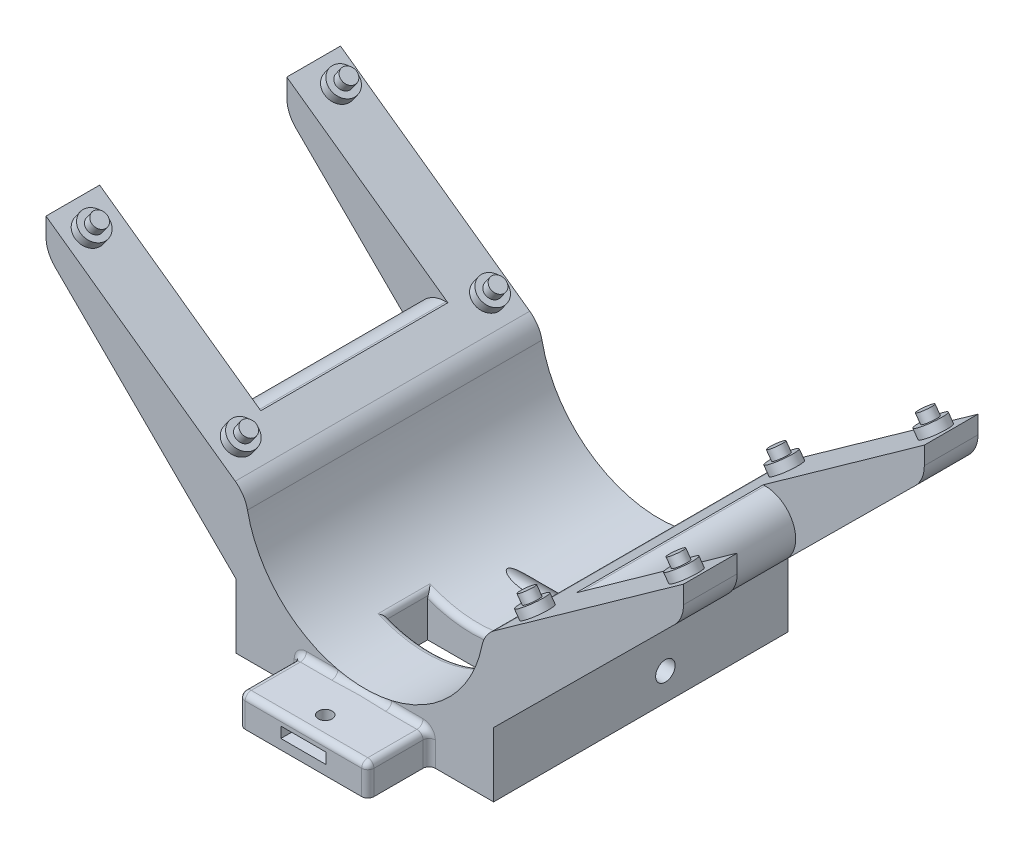
from build123d import *

# Parameters (mm, degrees)
BOSS_EXTRUDE1_DEPTH            = 48
CUT_EXTRUDE2_REACH             = 149.148
SKETCH2_W                      = 61
SKETCH2_H                      = 37.460856798
SKETCH2_R                      = 3.175
CUT_EXTRUDE2_DIRECTION_2_REACH = 149.148
CUT_EXTRUDE3_REACH             = 149.148
SKETCH4_W                      = 29
SKETCH4_H                      = 13
SKETCH5_W                      = 42
SKETCH5_H                      = 10
SKETCH5_W_2                    = 14.7
SKETCH5_H_2                    = 3.5
BOSS_EXTRUDE2_DEPTH            = 20
SKETCH6_R                      = 2.25
CUT_EXTRUDE4_DEPTH             = 150.07453327
FILLET1_R                      = 10
FILLET2_R                      = 2
FILLET4_R                      = 2
SKETCH7_R                      = 4.5
SKETCH7_R_2                    = 2.5
BOSS_EXTRUDE3_DEPTH            = 3
SKETCH7_3_R                    = 2.5
BOSS_EXTRUDE4_DEPTH            = 6


with BuildPart() as part:
    # Sketch1 → Boss-Extrude1 (new, symmetric)
    with BuildSketch(Plane.XY):
        with BuildLine():
            Line((-42, 0), (42, 0))
            Line((42, 0), (42, 21))
            Line((42, 21), (103.920275047, 82.460856798))
            Line((103.920275047, 82.460856798), (103.920275047, 92.460856798))
            Line((103.920275047, 92.460856798), (38.794329483, 46))
            ThreePointArc((38.794329483, 46), (0, 11), (-38.794329483, 46))
            Line((-38.794329483, 46), (-103.920275047, 92.460856798))
            Line((-103.920275047, 92.460856798), (-103.920275047, 82.460856798))
            Line((-103.920275047, 82.460856798), (-42, 21))
            Line((-42, 21), (-42, 0))
        make_face()
    extrude(amount=BOSS_EXTRUDE1_DEPTH, both=True)

    # Sketch2 → Cut-Extrude2 (cut, up to next)
    with BuildSketch(Plane(origin=(0, 0, 0), x_dir=(0, 0, -1), z_dir=(1, 0, 0)), mode=Mode.PRIVATE) as cut_extrude2_sk1:
        with Locations((0, 73.730428399)):
            Rectangle(SKETCH2_W, SKETCH2_H)
    cut_extrude2_tool1 = extrude(cut_extrude2_sk1.sketch, amount=-CUT_EXTRUDE2_REACH, mode=Mode.PRIVATE) & part.part
    # Sketch2 → Cut-Extrude2 (cut, up to next)
    with BuildSketch(Plane(origin=(0, 0, 0), x_dir=(0, 0, -1), z_dir=(1, 0, 0)), mode=Mode.PRIVATE) as cut_extrude2_sk2:
        with Locations((8, 9)):
            Circle(SKETCH2_R)
    cut_extrude2_tool2 = extrude(cut_extrude2_sk2.sketch, amount=-CUT_EXTRUDE2_REACH, mode=Mode.PRIVATE) & part.part
    add(cut_extrude2_tool1.solids().sort_by_distance((0, 73.730428, 0))[0], mode=Mode.SUBTRACT)
    add(cut_extrude2_tool2.solids().sort_by_distance((0, 9, -8))[0], mode=Mode.SUBTRACT)

    # Sketch2 → Cut-Extrude2 direction 2 (cut, up to next)
    with BuildSketch(Plane(origin=(0, 0, 0), x_dir=(0, 0, -1), z_dir=(1, 0, 0)), mode=Mode.PRIVATE) as cut_extrude2_direction_2_sk1:
        with Locations((0, 73.730428399)):
            Rectangle(SKETCH2_W, SKETCH2_H)
    cut_extrude2_direction_2_tool1 = extrude(cut_extrude2_direction_2_sk1.sketch, amount=CUT_EXTRUDE2_DIRECTION_2_REACH, mode=Mode.PRIVATE) & part.part
    # Sketch2 → Cut-Extrude2 direction 2 (cut, up to next)
    with BuildSketch(Plane(origin=(0, 0, 0), x_dir=(0, 0, -1), z_dir=(1, 0, 0)), mode=Mode.PRIVATE) as cut_extrude2_direction_2_sk2:
        with Locations((8, 9)):
            Circle(SKETCH2_R)
    cut_extrude2_direction_2_tool2 = extrude(cut_extrude2_direction_2_sk2.sketch, amount=CUT_EXTRUDE2_DIRECTION_2_REACH, mode=Mode.PRIVATE) & part.part
    add(cut_extrude2_direction_2_tool1.solids().sort_by_distance((0, 73.730428, 0))[0], mode=Mode.SUBTRACT)
    add(cut_extrude2_direction_2_tool2.solids().sort_by_distance((0, 9, -8))[0], mode=Mode.SUBTRACT)

    # Sketch4 → Cut-Extrude3 (cut, up to next)
    with BuildSketch(Plane(origin=(0, 0, 0), x_dir=(1, 0, 0), z_dir=(0, 1, 0)), mode=Mode.PRIVATE) as cut_extrude3_sk1:
        with Locations((0, -19.5)):
            Rectangle(SKETCH4_W, SKETCH4_H)
    cut_extrude3_tool1 = extrude(cut_extrude3_sk1.sketch, amount=CUT_EXTRUDE3_REACH, mode=Mode.PRIVATE) & part.part
    add(cut_extrude3_tool1.solids().sort_by_distance((0, 0, 19.5))[0], mode=Mode.SUBTRACT)

    # Sketch5 → Boss-Extrude2 (add)
    with BuildSketch(Plane.XY.offset(48)):
        with Locations((0, 5)):
            Rectangle(SKETCH5_W, SKETCH5_H)
        with Locations((0, 5)):
            Rectangle(SKETCH5_W_2, SKETCH5_H_2, mode=Mode.SUBTRACT)
    extrude(amount=BOSS_EXTRUDE2_DEPTH)

    # Sketch6 → Cut-Extrude4 (cut, through all)
    with BuildSketch(Plane(origin=(0, 10, 0), x_dir=(1, 0, 0), z_dir=(0, 1, 0))):
        with Locations((0, -60.885403607)):
            Circle(SKETCH6_R)
    extrude(amount=-CUT_EXTRUDE4_DEPTH, mode=Mode.SUBTRACT)

    # Fillet1
    fillet1_edges = [part.edges().sort_by_distance(p)[0] for p in [
        (103.920275047, 82.460856798, -39.25),
        (103.920275047, 82.460856798, 39.25),
        (76.254149084, 55, 0),
        (-103.920275047, 82.460856798, 39.25),
        (-103.920275047, 82.460856798, -39.25),
        (-76.254149084, 55, 0),
        (-38.794329483, 46, 0),
        (38.794329483, 46, 0),
    ]]
    fillet(fillet1_edges, radius=FILLET1_R)

    # Fillet2
    fillet2_edges = [part.edges().sort_by_distance(p)[0] for p in [
        (14.5, 13.795718485, 19.5),
        (0, 11, 13),
        (0, 11, 26),
        (-14.5, 13.795718485, 19.5),
    ]]
    fillet(fillet2_edges, radius=FILLET2_R)

    # Fillet4
    fillet4_edges = [part.edges().sort_by_distance(p)[0] for p in [
        (21, 5, 48),
        (21, 5, 68),
        (21, 10, 58),
        (-21, 10, 58),
        (0, 10, 68),
        (-21, 5, 68),
        (0, 10, 48),
        (-21, 5, 48),
    ]]
    fillet(fillet4_edges, radius=FILLET4_R)

    # Sketch7 → Boss-Extrude3 (add)
    # profile 1 of 4: a face of its own
    with BuildSketch(Plane(origin=(-8.663321552, 12.143706482, 0), x_dir=(0.8140743195533245, 0.5807607099690817, 0), z_dir=(-0.5807607099690816, 0.8140743195533244, 0))):
        with Locations((130.296460035, -40.5)):
            Circle(SKETCH7_R)
        with Locations((130.296460035, -40.5)):
            Circle(SKETCH7_R_2, mode=Mode.SUBTRACT)
    # profile 2 of 4: a face of its own
    with BuildSketch(Plane(origin=(-8.663321552, 12.143706482, 0), x_dir=(0.8140743195533245, 0.5807607099690817, 0), z_dir=(-0.5807607099690816, 0.8140743195533244, 0))):
        with Locations((70.606460035, -40.5)):
            Circle(SKETCH7_R)
        with Locations((70.606460035, -40.5)):
            Circle(SKETCH7_R_2, mode=Mode.SUBTRACT)
    # profile 3 of 4: a face of its own
    with BuildSketch(Plane(origin=(-8.663321552, 12.143706482, 0), x_dir=(0.8140743195533245, 0.5807607099690817, 0), z_dir=(-0.5807607099690816, 0.8140743195533244, 0))):
        with Locations((130.296460035, 40.78)):
            Circle(SKETCH7_R)
        with Locations((130.296460035, 40.78)):
            Circle(SKETCH7_R_2, mode=Mode.SUBTRACT)
    # profile 4 of 4: a face of its own
    with BuildSketch(Plane(origin=(-8.663321552, 12.143706482, 0), x_dir=(0.8140743195533245, 0.5807607099690817, 0), z_dir=(-0.5807607099690816, 0.8140743195533244, 0))):
        with Locations((70.606460035, 40.78)):
            Circle(SKETCH7_R)
        with Locations((70.606460035, 40.78)):
            Circle(SKETCH7_R_2, mode=Mode.SUBTRACT)
    boss_extrude3 = extrude(amount=BOSS_EXTRUDE3_DEPTH)

    # Sketch7_3 → Boss-Extrude4 (add)
    with BuildSketch(Plane(origin=(-8.663321552, 12.143706482, 0), x_dir=(0.8140743195533245, 0.5807607099690817, 0), z_dir=(-0.5807607099690816, 0.8140743195533244, 0))):
        with Locations((130.296460035, -40.5)):
            Circle(SKETCH7_3_R)
        with Locations((130.296460035, 40.78)):
            Circle(SKETCH7_3_R)
        with Locations((70.606460035, -40.5)):
            Circle(SKETCH7_3_R)
        with Locations((70.606460035, 40.78)):
            Circle(SKETCH7_3_R)
    boss_extrude4 = extrude(amount=BOSS_EXTRUDE4_DEPTH)

    # Mirror1: Boss-Extrude3, Boss-Extrude4 across plane
    add(boss_extrude3.mirror(Plane(origin=(0, 0, 0), x_dir=(0, 0, 1), z_dir=(1, 0, 0))))
    add(boss_extrude4.mirror(Plane(origin=(0, 0, 0), x_dir=(0, 0, 1), z_dir=(1, 0, 0))))


solid = part.part
